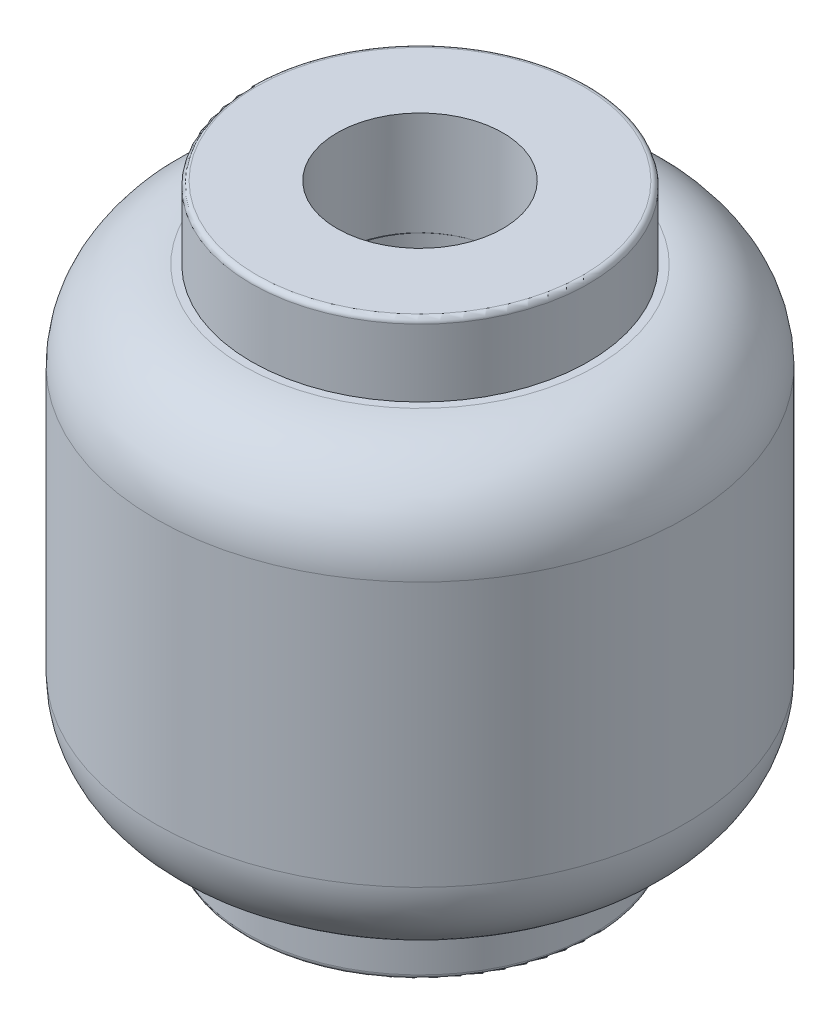
from build123d import *

# Parameters (mm, degrees)
SKETCH2_R          = 1.6
CUT_EXTRUDE1_DEPTH = 2
CUT_EXTRUDE3_DEPTH = 9
CIRPATTERN1_COUNT  = 3
SKETCH5_R          = 2.45
CUT_EXTRUDE4_DEPTH = 8.5
SKETCH6_R          = 0.5
CUT_EXTRUDE5_DEPTH = 8.5
CUT_EXTRUDE6_DEPTH = 8.5


with BuildPart() as part:
    # Sketch1 → Revolve1 (revolve)
    with BuildSketch(Plane.XY):
        with BuildLine():
            Line((0, -13.977445887), (3.15, -13.977445887))
            ThreePointArc((3.15, -13.977445887), (3.220710678, -14.006735209), (3.25, -14.077445887))
            Line((3.25, -14.077445887), (3.25, -15.377445887))
            Line((3.25, -15.377445887), (3.4, -15.377445887))
            ThreePointArc((3.4, -15.377445887), (4.602081528, -15.875364359), (5.1, -17.077445887))
            Line((5.1, -17.077445887), (5.1, -22.177445887))
            ThreePointArc((5.1, -22.177445887), (4.602081528, -23.379527415), (3.4, -23.877445887))
            Line((3.4, -23.877445887), (3.35, -23.877445887))
            Line((3.35, -23.877445887), (3.35, -24.877445887))
            ThreePointArc((3.35, -24.877445887), (3.320710678, -24.948156565), (3.25, -24.977445887))
            Line((3.25, -24.977445887), (0, -24.977445887))
            Line((0, -24.977445887), (0, -13.977445887))
        make_face()
    revolve(axis=Axis((0, 36.866666667, 0), (0, -1, 0)))

    # Sketch2 → Cut-Extrude1 (cut)
    with BuildSketch(Plane(origin=(0, -13.977445887, 0), x_dir=(1, 0, 0), z_dir=(0, 1, 0))):
        Circle(SKETCH2_R)
    extrude(amount=-CUT_EXTRUDE1_DEPTH, mode=Mode.SUBTRACT)

    # Sketch4 → Cut-Extrude3 (cut)
    with BuildSketch(Plane(origin=(0, -15.977445887, 0), x_dir=(1, 0, 0), z_dir=(0, 1, 0))):
        with BuildLine():
            Line((-0.42, 0.319853318), (-0.42, 1.543891188))
            ThreePointArc((-0.42, 1.543891188), (-1.354595532, 0.832929416), (-1.539787712, -0.326656419))
            Line((-1.539787712, -0.326656419), (-0.42, 0.319853318))
        make_face()
    cut_extrude3 = extrude(amount=-CUT_EXTRUDE3_DEPTH, mode=Mode.SUBTRACT)

    # CirPattern1: Cut-Extrude3 ×3 about axis
    cirpattern1_axis = Axis((0, 0, -0.022012107), (0, 1, 0))
    for i in range(1, CIRPATTERN1_COUNT):
        add(cut_extrude3.rotate(cirpattern1_axis, i * 360 / CIRPATTERN1_COUNT), mode=Mode.SUBTRACT)

    # Sketch5 → Cut-Extrude4 (cut)
    with BuildSketch(Plane.XZ.offset(24.977445887)):
        Circle(SKETCH5_R)
    extrude(amount=-CUT_EXTRUDE4_DEPTH, mode=Mode.SUBTRACT)

    # Sketch6 → Cut-Extrude5 (cut)
    with BuildSketch(Plane(origin=(0, 0, 0), x_dir=(0, 0, -1), z_dir=(1, 0, 0))):
        with Locations((-2.1, -18.477445887)):
            Circle(SKETCH6_R)
        with Locations((2.1, -18.477445887)):
            Circle(SKETCH6_R)
    extrude(amount=-CUT_EXTRUDE5_DEPTH, mode=Mode.SUBTRACT)

    # Sketch7 → Cut-Extrude6 (cut)
    with BuildSketch(Plane(origin=(0, 0, 0), x_dir=(0, 0, -1), z_dir=(1, 0, 0))):
        with BuildLine():
            Line((1.502497593, -21.270117784), (-1.5, -21.270117784))
            ThreePointArc((-1.5, -21.270117784), (-1.846335949, -20.923781835), (-1.5, -20.577445887))
            Line((-1.5, -20.577445887), (1.502497593, -20.577445887))
            ThreePointArc((1.502497593, -20.577445887), (1.848833542, -20.923781835), (1.502497593, -21.270117784))
        make_face()
    extrude(amount=-CUT_EXTRUDE6_DEPTH, mode=Mode.SUBTRACT)


solid = part.part
